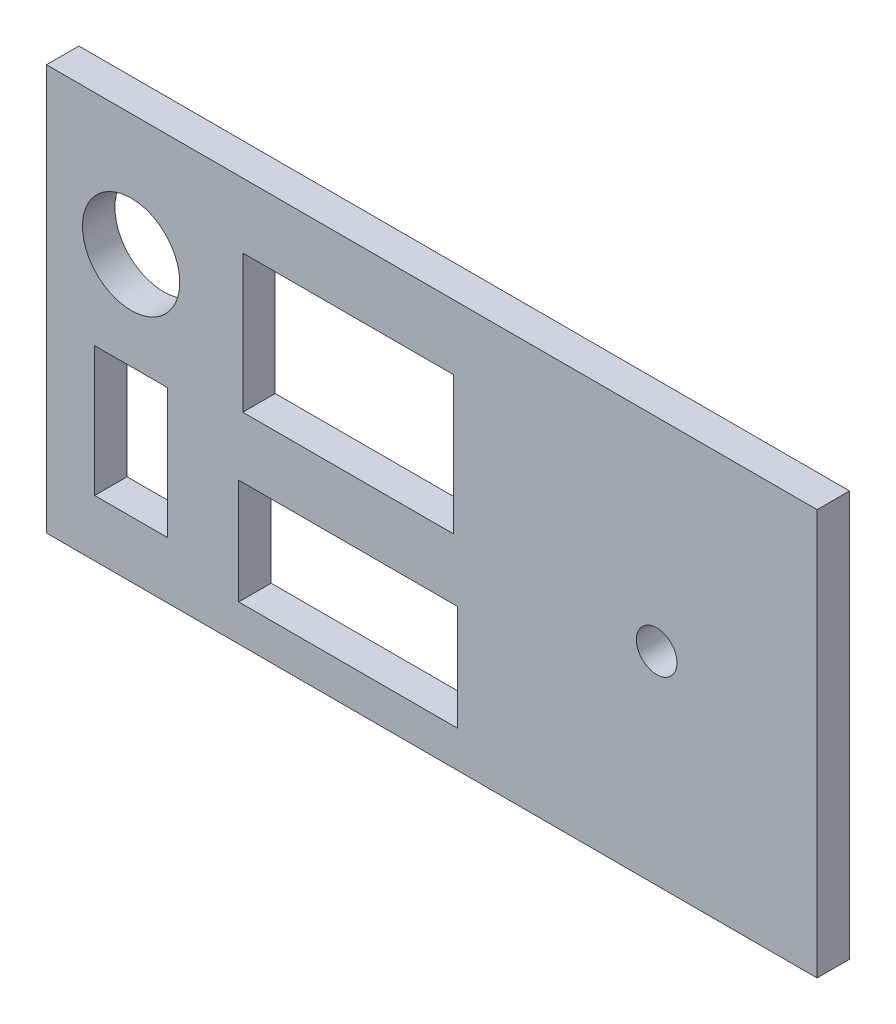
from build123d import *

# Parameters (mm, degrees)
SKETCH3_W           = 95
SKETCH3_H           = 50
SKETCH3_RX          = 2.5
SKETCH3_RY          = 2.5
SKETCH3_RX_2        = 6
SKETCH3_RY_2        = 6
SKETCH3_W_2         = 26
SKETCH3_H_2         = 17
SKETCH3_W_3         = 27
SKETCH3_H_3         = 13
SKETCH3_W_4         = 9
SKETCH3_H_4         = 16
BOSS_EXTRUDE2_DEPTH = 4


with BuildPart() as part:
    # Sketch3 → Boss-Extrude2 (new body)
    with BuildSketch(Plane.XY):
        with Locations((-63.7985, -48.7036)):
            Rectangle(SKETCH3_W, SKETCH3_H)
        with Locations(Location((-36.0722, -48.7036), (0, 0, 90))):
            Ellipse(SKETCH3_RX, SKETCH3_RY, mode=Mode.SUBTRACT)
        with Locations(Location((-100.8596, -38.7221), (0, 0, 180))):
            Ellipse(SKETCH3_RX_2, SKETCH3_RY_2, mode=Mode.SUBTRACT)
        with Locations((-74.0985, -40.2036)):
            Rectangle(SKETCH3_W_2, SKETCH3_H_2, mode=Mode.SUBTRACT)
        with Locations((-74.0985, -62.7036)):
            Rectangle(SKETCH3_W_3, SKETCH3_H_3, mode=Mode.SUBTRACT)
        with Locations((-100.8596, -58.7221)):
            Rectangle(SKETCH3_W_4, SKETCH3_H_4, mode=Mode.SUBTRACT)
    extrude(amount=BOSS_EXTRUDE2_DEPTH)


solid = part.part
